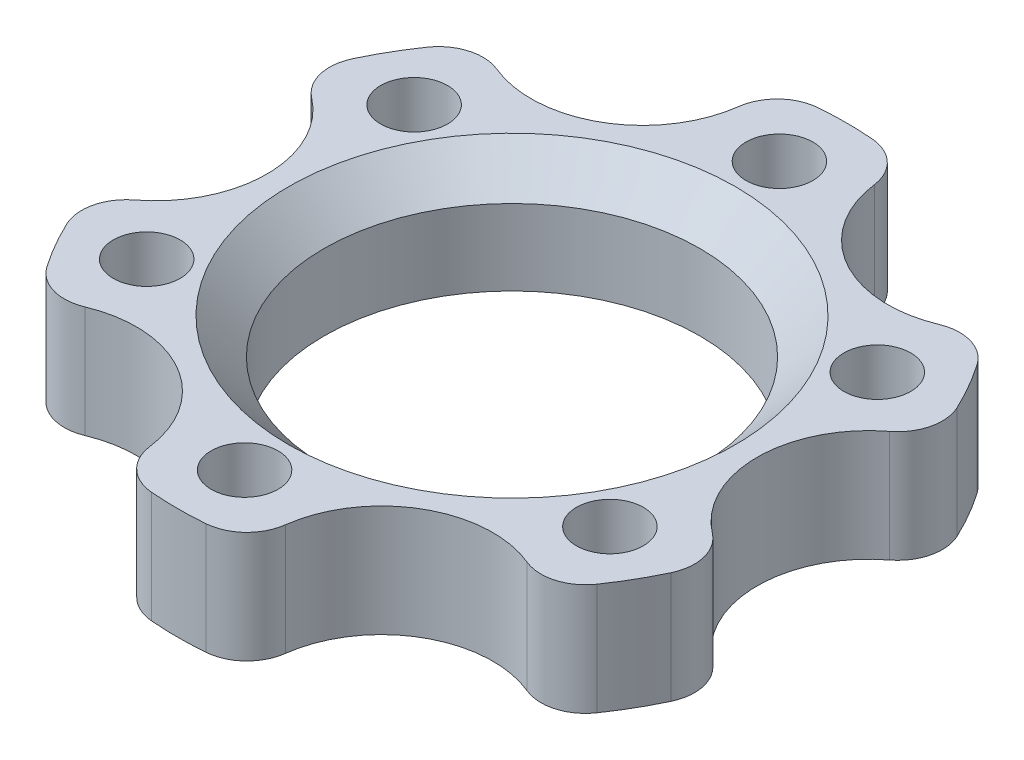
from build123d import *

# Parameters (mm, degrees)
SKETCH1_W               = 20.865197439
SKETCH1_H               = 9.525
SKETCH2_R               = 4.7625
SKETCH2_R_2             = 15.875
CUT_EXTRUDE1_DEPTH      = 16.875
CUT_EXTRUDE1_DEPTH_BACK = 1
FILLET1_R               = 6.35


with BuildPart() as part:
    # Sketch1 → Revolve1 (revolve)
    with BuildSketch(Plane.XY):
        Polygon((31.839802561, 6.35), (26.759802561, 1.27), (26.759802561, 0), (47.625, 0), (47.625, 6.35), align=None)
        with Locations((37.192401281, -4.7625)):
            Rectangle(SKETCH1_W, SKETCH1_H)
    revolve(axis=Axis((0, 0, 0), (0, 1, 0)))

    # Sketch2 → Cut-Extrude1 (cut, two sides)
    with BuildSketch(Plane(origin=(0, 6.35, 0), x_dir=(-1, 0, 0), z_dir=(0, -1, 0))) as cut_extrude1_sk:
        with Locations((0, 38.1)):
            Circle(SKETCH2_R)
        with Locations((32.995567884, 19.05)):
            Circle(SKETCH2_R)
        with Locations((32.995567884, -19.05)):
            Circle(SKETCH2_R)
        with Locations((0, -38.1)):
            Circle(SKETCH2_R)
        with Locations((-32.995567884, -19.05)):
            Circle(SKETCH2_R)
        with Locations((-32.995567884, 19.05)):
            Circle(SKETCH2_R)
        with Locations((50.8, 0)):
            Circle(SKETCH2_R_2)
        with Locations((25.4, -43.994090512)):
            Circle(SKETCH2_R_2)
        with Locations((-25.4, -43.994090512)):
            Circle(SKETCH2_R_2)
        with Locations((-50.8, 0)):
            Circle(SKETCH2_R_2)
        with Locations((-25.4, 43.994090512)):
            Circle(SKETCH2_R_2)
        with Locations((25.4, 43.994090512)):
            Circle(SKETCH2_R_2)
    extrude(amount=CUT_EXTRUDE1_DEPTH, mode=Mode.SUBTRACT)
    extrude(cut_extrude1_sk.sketch, amount=-CUT_EXTRUDE1_DEPTH_BACK, mode=Mode.SUBTRACT)

    # Fillet1
    fillet1_edges = [part.edges().sort_by_distance(p)[0] for p in [
        (-35.500453462, -1.5875, 31.746786121),
        (-9.743296538, -1.5875, 46.617687604),
        (-45.24375, -1.5875, -14.870901484),
        (-45.24375, -1.5875, 14.870901484),
        (9.743296538, -1.5875, 46.617687604),
        (35.500453462, -1.5875, 31.746786121),
        (45.24375, -1.5875, 14.870901484),
        (45.24375, -1.5875, -14.870901484),
        (35.500453462, -1.5875, -31.746786121),
        (9.743296538, -1.5875, -46.617687604),
        (-9.743296538, -1.5875, -46.617687604),
        (-35.500453462, -1.5875, -31.746786121),
    ]]
    fillet(fillet1_edges, radius=FILLET1_R)


solid = part.part
